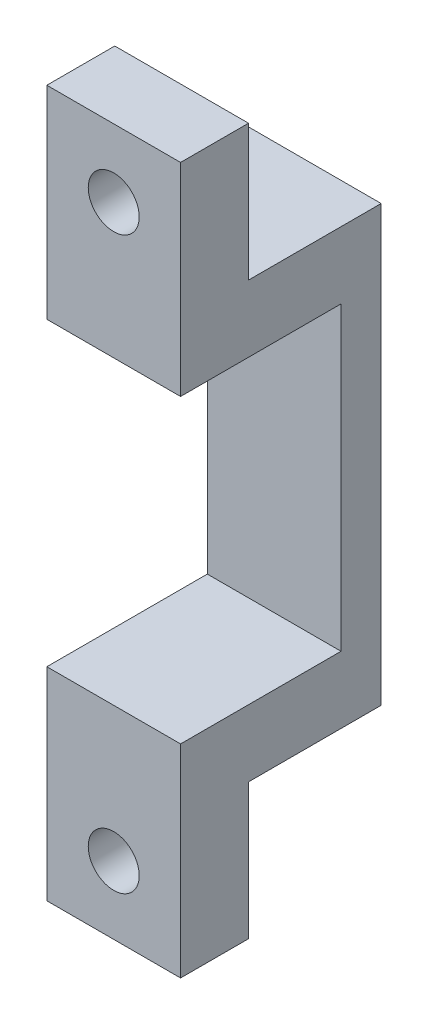
from build123d import *

# Parameters (mm, degrees)
SKETCH1_W                  = 26.40999036
SKETCH1_H                  = 14.9999954
BOSS_EXTRUDE1_DEPTH        = 10.0000054
SKETCH2_W                  = 12.0000014
SKETCH2_H                  = 11.25000036
CUT_EXTRUDE1_DEPTH         = 11.0000054
SKETCH3_W                  = 9.9199954
SKETCH3_H                  = 10.16
CUT_EXTRUDE2_DEPTH         = 11.0000054
M3_5_CLEARANCE_HOLE1_D     = 3.81
M3_5_CLEARANCE_HOLE1_DEPTH = 5.08


with BuildPart() as part:
    # Sketch1 → Boss-Extrude1 (new body)
    with BuildSketch(Plane(origin=(0, 0, 0), x_dir=(0, -1, 0), z_dir=(-1, 0, 0))):
        with Locations((-1.95499482, 7.4999977)):
            Rectangle(SKETCH1_W, SKETCH1_H)
    boss_extrude1 = extrude(amount=-BOSS_EXTRUDE1_DEPTH)

    # Sketch2 → Cut-Extrude1 (cut, through all)
    with BuildSketch(Plane(origin=(10.0000054, 0, 0), x_dir=(0, 0, -1), z_dir=(1, 0, 0))):
        with Locations((-8.9999947, -5.62500018)):
            Rectangle(SKETCH2_W, SKETCH2_H)
    cut_extrude1 = extrude(amount=-CUT_EXTRUDE1_DEPTH, mode=Mode.SUBTRACT)

    # Sketch3 → Cut-Extrude2 (cut, through all)
    with BuildSketch(Plane(origin=(10.0000054, 0, 0), x_dir=(0, 0, -1), z_dir=(1, 0, 0))):
        with Locations((-4.9599977, 10.07999)):
            Rectangle(SKETCH3_W, SKETCH3_H)
    cut_extrude2 = extrude(amount=-CUT_EXTRUDE2_DEPTH, mode=Mode.SUBTRACT)

    # M3.5 Clearance Hole1
    with Locations(Plane(origin=(0, 0, 9.9199954), x_dir=(-1, 0, 0), z_dir=(0, 0, -1))):
        with Locations((-4.99999, 10.07999)):
            m3_5_clearance_hole1 = Hole(M3_5_CLEARANCE_HOLE1_D / 2, depth=M3_5_CLEARANCE_HOLE1_DEPTH)

    # Sketch6 → Ø1.2 (1.2) Diameter Hole1 (revolve, cut)
    with BuildSketch(Plane(origin=(0, 2.50000008, 9.4881954), x_dir=(0, 0, 1), z_dir=(0, 1, 0))):
        Polygon((0, 0), (0, 5.360506413), (0.60000007, 4.99999), (0.60000007, 0), align=None)
    f_1_2_1_2_diameter_hole1 = revolve(axis=Axis((-6.35, 2.50000008, 9.4881954), (1, 0, 0)), mode=Mode.SUBTRACT)

    # Mirror1: Boss-Extrude1, Cut-Extrude1, Cut-Extrude2, M3.5 Clearance Hole1, Ø1.2 (1.2) Diameter Hole1 across plane
    add(boss_extrude1.mirror(Plane(origin=(0, -11.25000036, 0), x_dir=(0, 0, 1), z_dir=(0, -1, 0))))
    add(cut_extrude1.mirror(Plane(origin=(0, -11.25000036, 0), x_dir=(0, 0, 1), z_dir=(0, -1, 0))), mode=Mode.SUBTRACT)
    add(cut_extrude2.mirror(Plane(origin=(0, -11.25000036, 0), x_dir=(0, 0, 1), z_dir=(0, -1, 0))), mode=Mode.SUBTRACT)
    add(m3_5_clearance_hole1.mirror(Plane(origin=(0, -11.25000036, 0), x_dir=(0, 0, 1), z_dir=(0, -1, 0))), mode=Mode.SUBTRACT)
    add(f_1_2_1_2_diameter_hole1.mirror(Plane(origin=(0, -11.25000036, 0), x_dir=(0, 0, 1), z_dir=(0, -1, 0))), mode=Mode.SUBTRACT)


solid = part.part
